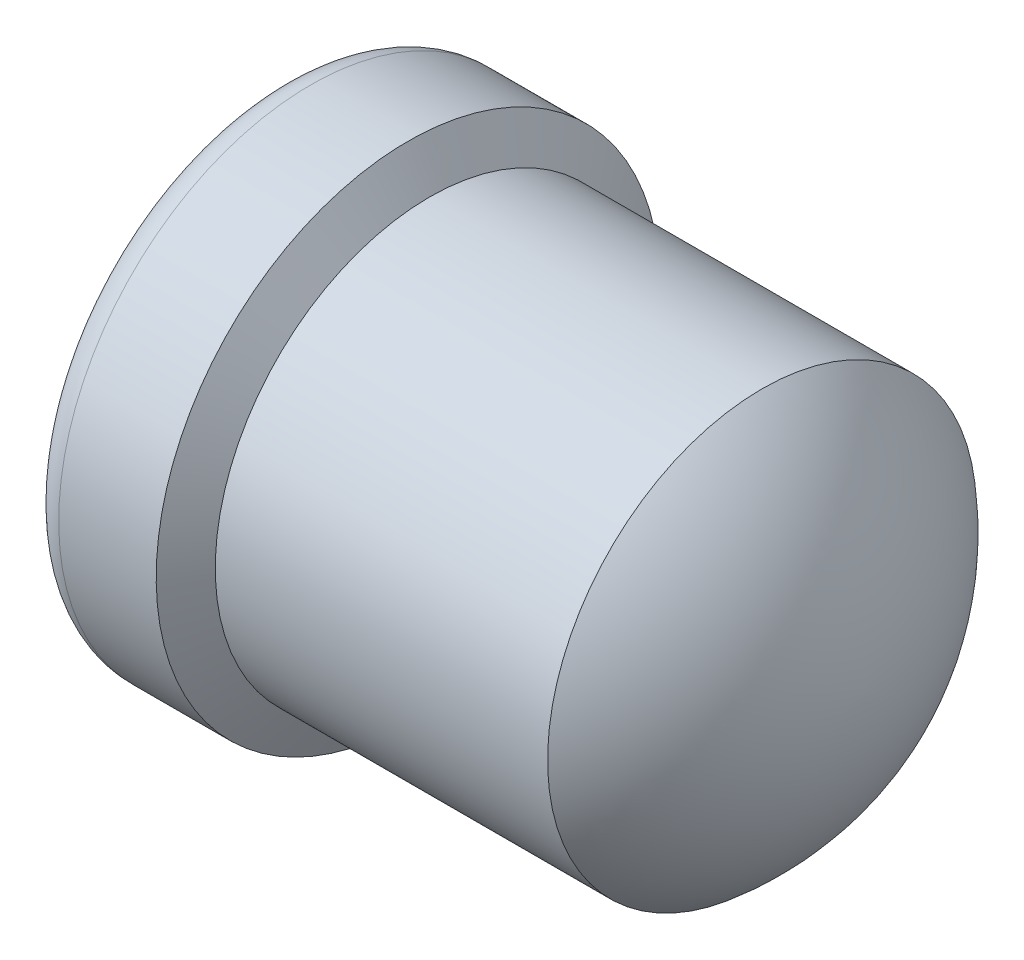
from build123d import *

# Parameters (mm, degrees)
HOLE1_D           = 0.9144
HOLE1_DEPTH       = 1.016
HOLE1_CSINK_D     = 1.0922
HOLE1_CSINK_ANGLE = 60
HOLE1_TIP         = 0.274713475


with BuildPart() as part:
    # Sketch1 → RevolutionAngle1 (revolve)
    with BuildSketch(Plane.XY):
        with BuildLine():
            Line((0, 0), (0, 0.54737))
            ThreePointArc((0, 0.54737), (0.022318463, 0.601251537), (0.0762, 0.62357))
            Line((0.0762, 0.62357), (0.3175, 0.62357))
            Line((0.3175, 0.62357), (0.371026143, 0.53086))
            Line((0.371026143, 0.53086), (1.1938, 0.53086))
            ThreePointArc((1.1938, 0.53086), (1.37828421, 0.292934407), (1.4478, 0))
            Line((1.4478, 0), (0, 0))
        make_face()
    revolve(axis=Axis((0, 0, 0), (1, 0, 0)))

    # Hole1
    with Locations(Plane.ZY):
        with Locations((0, 0)):
            CounterSinkHole(HOLE1_D / 2, HOLE1_CSINK_D / 2, depth=HOLE1_DEPTH, counter_sink_angle=HOLE1_CSINK_ANGLE)
            with Locations((0, 0, -(HOLE1_DEPTH + HOLE1_TIP / 2))):  # 118° drill point
                Cone(0, HOLE1_D / 2, HOLE1_TIP, mode=Mode.SUBTRACT)


solid = part.part
